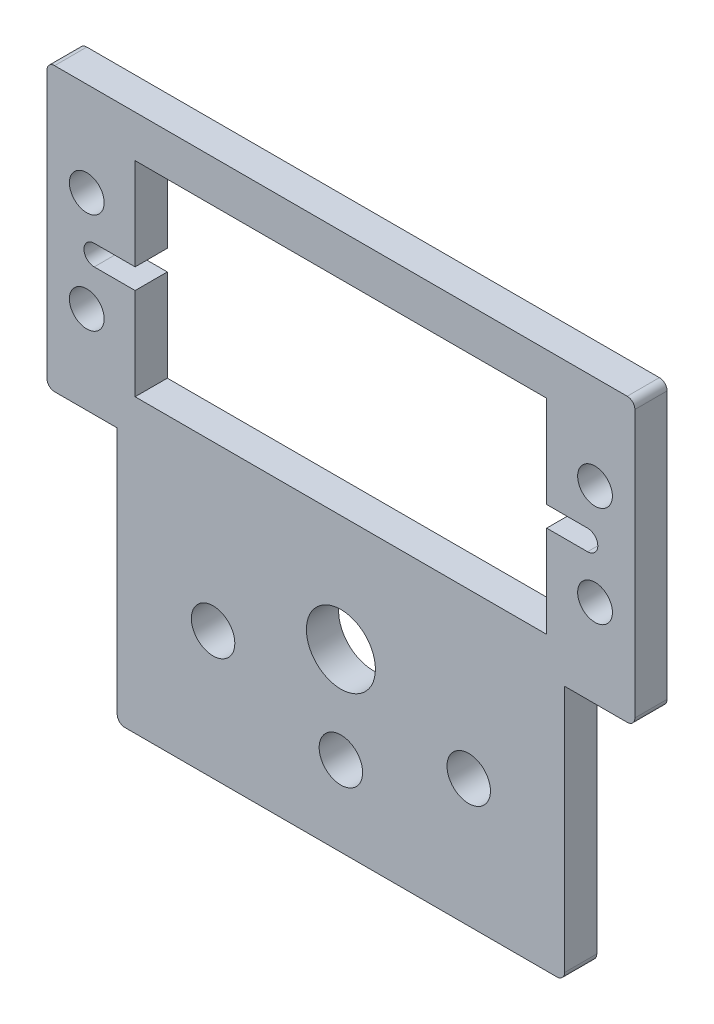
from build123d import *

# Parameters (mm, degrees)
SKETCH1_R           = 2.159
SKETCH1_R_2         = 1.7272
SKETCH1_R_3         = 3.429
SKETCH1_W           = 40.894
SKETCH1_H           = 20.32
BOSS_EXTRUDE1_DEPTH = 3.2004
CUT_EXTRUDE1_DEPTH  = 3.2004
FILLET1_R           = 0.762


with BuildPart() as part:
    # Sketch1 → Boss-Extrude1 (new body)
    with BuildSketch(Plane.XY):
        Polygon((0, 0), (44.45, 0), (44.45, 25.4), (51.435, 25.4), (51.435, 53.464659022), (-6.985, 53.464659022), (-6.985, 25.4), (0, 25.4), align=None)
        with Locations((9.525, 12.7)):
            Circle(SKETCH1_R, mode=Mode.SUBTRACT)
        with Locations((34.925, 12.7)):
            Circle(SKETCH1_R, mode=Mode.SUBTRACT)
        with Locations((47.475, 34.131115311)):
            Circle(SKETCH1_R_2, mode=Mode.SUBTRACT)
        with Locations((-3.025, 44.131115311)):
            Circle(SKETCH1_R_2, mode=Mode.SUBTRACT)
        with Locations((-3.025, 34.131115311)):
            Circle(SKETCH1_R_2, mode=Mode.SUBTRACT)
        with Locations((47.475, 44.131115311)):
            Circle(SKETCH1_R_2, mode=Mode.SUBTRACT)
        with Locations((22.225, 17.4625)):
            Circle(SKETCH1_R_3, mode=Mode.SUBTRACT)
        with Locations((22.225, 7.9375)):
            Circle(SKETCH1_R, mode=Mode.SUBTRACT)
        with Locations((22.225, 39.131115311)):
            Rectangle(SKETCH1_W, SKETCH1_H, mode=Mode.SUBTRACT)
    extrude(amount=BOSS_EXTRUDE1_DEPTH)

    # Sketch2 → Cut-Extrude1 (cut)
    with BuildSketch(Plane.XY.offset(3.2004)):
        with BuildLine():
            Line((-2.286, 40.147115311), (1.778, 40.147115311))
            Line((1.778, 40.147115311), (1.778, 38.115115311))
            Line((1.778, 38.115115311), (-2.286, 38.115115311))
            ThreePointArc((-2.286, 38.115115311), (-3.302, 39.131115311), (-2.286, 40.147115311))
        make_face()
        with BuildLine():
            Line((42.672, 40.147115311), (46.736, 40.147115311))
            ThreePointArc((46.736, 40.147115311), (47.752, 39.131115311), (46.736, 38.115115311))
            Line((46.736, 38.115115311), (42.672, 38.115115311))
            Line((42.672, 38.115115311), (42.672, 40.147115311))
        make_face()
    extrude(amount=-CUT_EXTRUDE1_DEPTH, mode=Mode.SUBTRACT)

    # Fillet1
    fillet1_edges = [part.edges().sort_by_distance(p)[0] for p in [
        (51.435, 53.464659022, 1.6002),
        (51.435, 25.4, 1.6002),
        (44.45, 0, 1.6002),
        (0, 0, 1.6002),
        (-6.985, 25.4, 1.6002),
        (-6.985, 53.464659022, 1.6002),
    ]]
    fillet(fillet1_edges, radius=FILLET1_R)


solid = part.part
